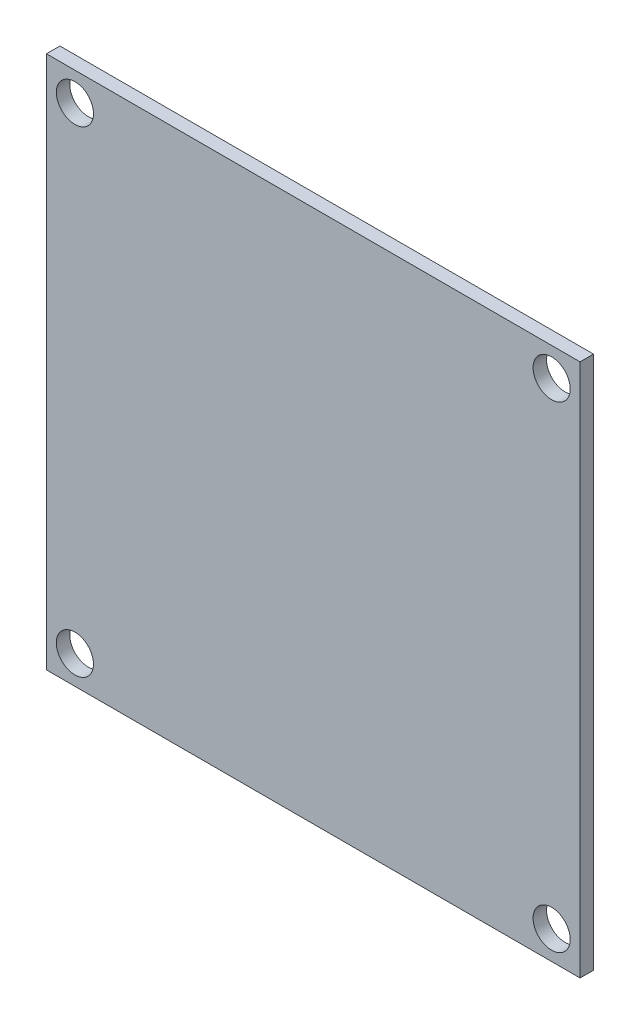
from build123d import *

# Parameters (mm, degrees)
SKETCH1_W           = 50.3682
SKETCH1_H           = 50.3682
SKETCH1_R           = 1.7526
BOSS_EXTRUDE1_DEPTH = 1.27


with BuildPart() as part:
    # Sketch1 → Boss-Extrude1 (new body)
    with BuildSketch(Plane.XY):
        Rectangle(SKETCH1_W, SKETCH1_H)
        with Locations((-22.5, 22.5)):
            Circle(SKETCH1_R, mode=Mode.SUBTRACT)
        with Locations((22.5, 22.5)):
            Circle(SKETCH1_R, mode=Mode.SUBTRACT)
        with Locations((-22.5, -22.5)):
            Circle(SKETCH1_R, mode=Mode.SUBTRACT)
        with Locations((22.5, -22.5)):
            Circle(SKETCH1_R, mode=Mode.SUBTRACT)
    extrude(amount=BOSS_EXTRUDE1_DEPTH)


solid = part.part
